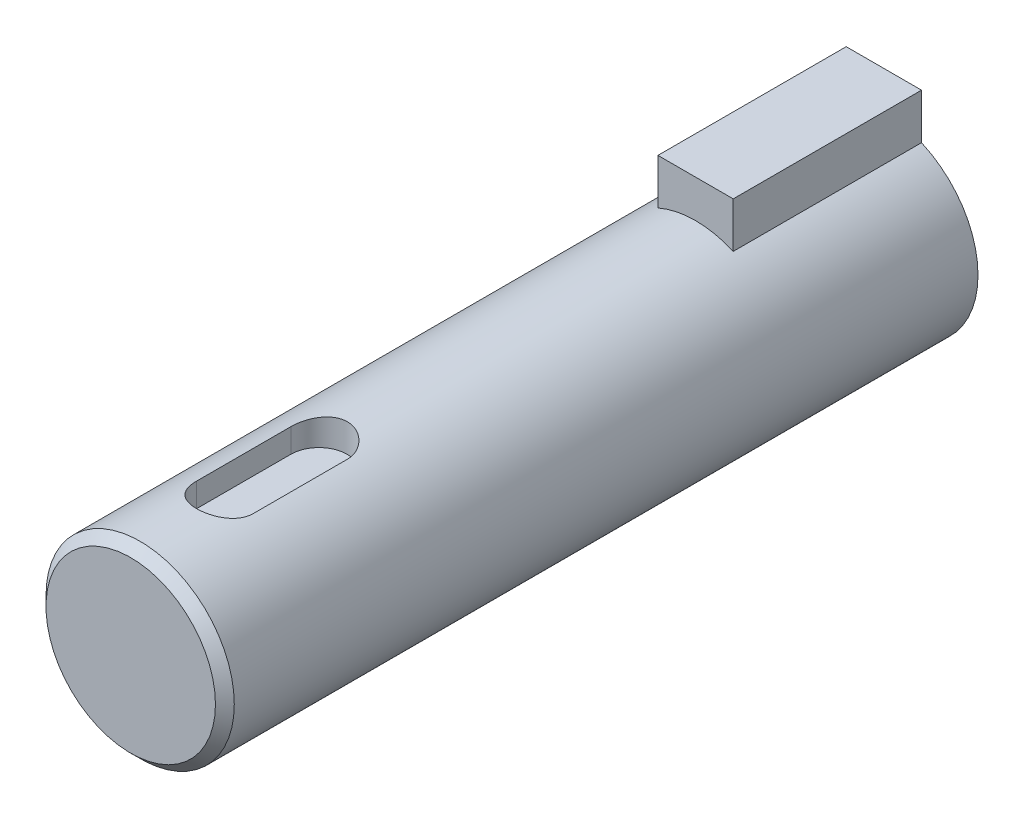
from build123d import *

# Parameters (mm, degrees)
BOSS_EXTRUDE1_DEPTH = 10
SKETCH2_R           = 5
BOSS_EXTRUDE2_DEPTH = 30
CUT_EXTRUDE1_START  = 3.5
CUT_EXTRUDE1_DEPTH  = 4.5
CHAMFER1_SIZE       = 0.5


with BuildPart() as part:
    # Sketch1 → Boss-Extrude1 (new body)
    with BuildSketch(Plane.XY):
        with BuildLine():
            Line((-2, 7), (2, 7))
            Line((2, 7), (2, 4.582575695))
            ThreePointArc((2, 4.582575695), (0, -5), (-2, 4.582575695))
            Line((-2, 4.582575695), (-2, 7))
        make_face()
    extrude(amount=BOSS_EXTRUDE1_DEPTH)

    # Sketch2 → Boss-Extrude2 (add)
    with BuildSketch(Plane.XY.offset(10)):
        Circle(SKETCH2_R)
    extrude(amount=BOSS_EXTRUDE2_DEPTH)

    # Sketch3 → Cut-Extrude1 (cut, through all)
    with BuildSketch(Plane(origin=(0, 0, 0), x_dir=(1, 0, 0), z_dir=(0, 1, 0)).offset(CUT_EXTRUDE1_START)):
        with BuildLine():
            Line((1.5, -30), (1.5, -35))
            ThreePointArc((1.5, -35), (0, -36.5), (-1.5, -35))
            Line((-1.5, -35), (-1.5, -30))
            ThreePointArc((-1.5, -30), (0, -28.5), (1.5, -30))
        make_face()
    extrude(amount=CUT_EXTRUDE1_DEPTH, mode=Mode.SUBTRACT)

    # Chamfer1
    chamfer1_edges = [part.edges().sort_by_distance(p)[0] for p in [
        (-5, 0, 40),
    ]]
    chamfer(chamfer1_edges, length=CHAMFER1_SIZE)


solid = part.part
